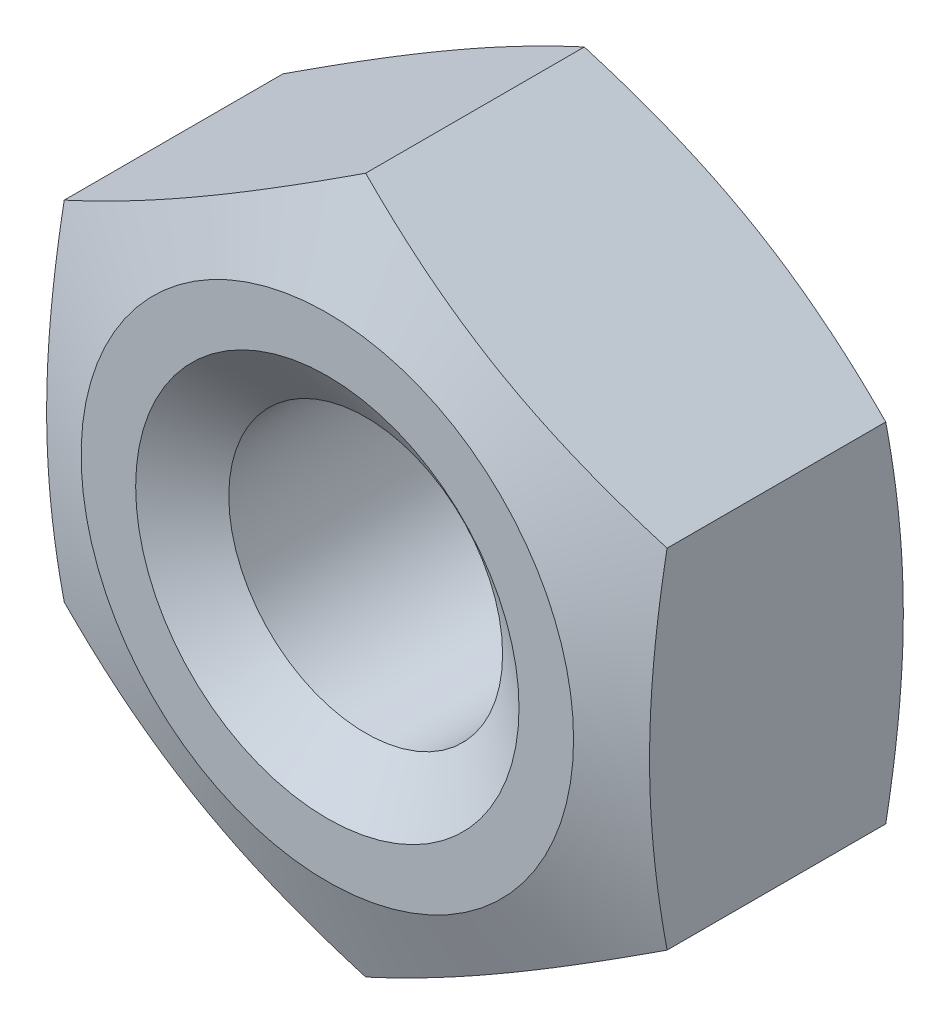
from build123d import *

# Parameters (mm, degrees)
BASENUTSKE_R  = 3.96875
BASENUT_DEPTH = 8.5598


with BuildPart() as part:
    # BaseNutSke → BaseNut (new body)
    with BuildSketch(Plane.XY):
        Polygon((8.7376, 5.044655712), (8.7376, -5.044655712), (0, -10.089311424), (-8.7376, -5.044655712), (-8.7376, 5.044655712), (0, 10.089311424), align=None)
        Circle(BASENUTSKE_R, mode=Mode.SUBTRACT)
    extrude(amount=-BASENUT_DEPTH)

    # Sketch3 → Double-Chamfer (revolve, cut)
    with BuildSketch(Plane(origin=(0, 0, 0), x_dir=(0, 0, -1), z_dir=(1, 0, 0))):
        Polygon((8.5598, 7.1374), (7.44855, 10.089311424), (7.44855, 22.789311424), (21.2598, 22.789311424), (21.2598, 7.1374), align=None)
        Polygon((1.11125, 22.789311424), (-12.7, 22.789311424), (-12.7, 7.1374), (0, 7.1374), (1.11125, 10.089311424), align=None)
    revolve(axis=Axis((0, 0, 0), (0, 0, -1)), mode=Mode.SUBTRACT)

    # Sketch5 → EndChamfer (revolve, cut)
    with BuildSketch(Plane(origin=(0, 0, 0), x_dir=(0, 0, -1), z_dir=(1, 0, 0))):
        Polygon((8.5344, 5.55625), (7.311662586, 3.81), (8.5852, 3.81), (8.5852, 5.55625), align=None)
        Polygon((-0.0508, 5.55625), (0, 5.55625), (1.222737414, 3.81), (-0.0508, 3.81), align=None)
    revolve(axis=Axis((0, 0, -25.037505729), (0, 0, -1)), mode=Mode.SUBTRACT)


solid = part.part
